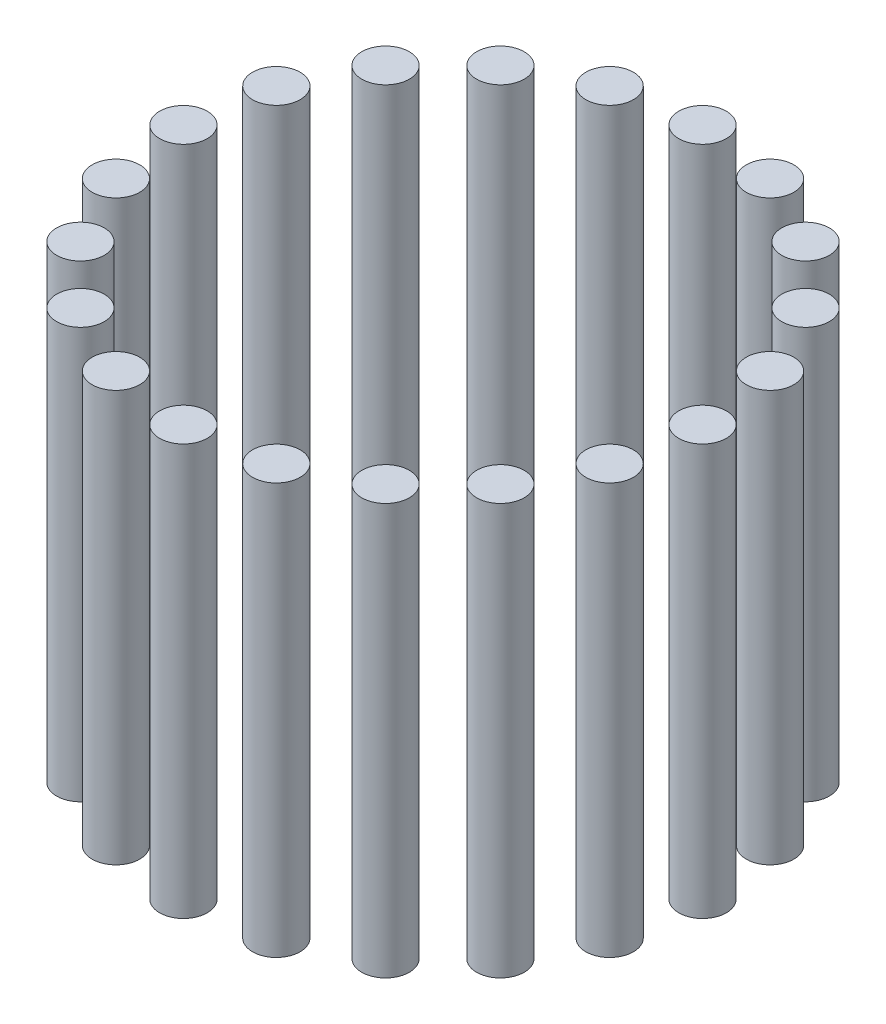
from build123d import *

# Parameters (mm, degrees)
SKETCH1_R              = 5.5
BOSS_EXTRUDE1_DEPTH    = 95
BOSS_EXTRUDE1_2_DEPTH  = 95
BOSS_EXTRUDE1_3_DEPTH  = 95
BOSS_EXTRUDE1_4_DEPTH  = 95
BOSS_EXTRUDE1_5_DEPTH  = 95
BOSS_EXTRUDE1_6_DEPTH  = 95
BOSS_EXTRUDE1_7_DEPTH  = 95
BOSS_EXTRUDE1_8_DEPTH  = 95
BOSS_EXTRUDE1_9_DEPTH  = 95
BOSS_EXTRUDE1_10_DEPTH = 95
BOSS_EXTRUDE1_11_DEPTH = 95
BOSS_EXTRUDE1_12_DEPTH = 95
BOSS_EXTRUDE1_13_DEPTH = 95
BOSS_EXTRUDE1_14_DEPTH = 95
BOSS_EXTRUDE1_15_DEPTH = 95
BOSS_EXTRUDE1_16_DEPTH = 95
BOSS_EXTRUDE1_17_DEPTH = 95
BOSS_EXTRUDE1_18_DEPTH = 95
BOSS_EXTRUDE1_19_DEPTH = 95
BOSS_EXTRUDE1_20_DEPTH = 95


with BuildPart() as part:
    # Sketch1 → Boss-Extrude1 (new body)
    with BuildSketch(Plane(origin=(0, 0, 0), x_dir=(1, 0, 0), z_dir=(0, 1, 0))):
        with Locations((-60, 0)):
            Circle(SKETCH1_R)
    extrude(amount=BOSS_EXTRUDE1_DEPTH)


with BuildPart() as body_2:
    # Sketch1 → Boss-Extrude1 2 (new body)
    with BuildSketch(Plane(origin=(0, 0, 0), x_dir=(1, 0, 0), z_dir=(0, 1, 0))):
        with Locations((-57.063390978, 18.541019662)):
            Circle(SKETCH1_R)
    extrude(amount=BOSS_EXTRUDE1_2_DEPTH)


with BuildPart() as body_3:
    # Sketch1 → Boss-Extrude1 3 (new body)
    with BuildSketch(Plane(origin=(0, 0, 0), x_dir=(1, 0, 0), z_dir=(0, 1, 0))):
        with Locations((-48.541019662, 35.267115138)):
            Circle(SKETCH1_R)
    extrude(amount=BOSS_EXTRUDE1_3_DEPTH)


with BuildPart() as body_4:
    # Sketch1 → Boss-Extrude1 4 (new body)
    with BuildSketch(Plane(origin=(0, 0, 0), x_dir=(1, 0, 0), z_dir=(0, 1, 0))):
        with Locations((-35.267115138, 48.541019662)):
            Circle(SKETCH1_R)
    extrude(amount=BOSS_EXTRUDE1_4_DEPTH)


with BuildPart() as body_5:
    # Sketch1 → Boss-Extrude1 5 (new body)
    with BuildSketch(Plane(origin=(0, 0, 0), x_dir=(1, 0, 0), z_dir=(0, 1, 0))):
        with Locations((-18.541019662, 57.063390978)):
            Circle(SKETCH1_R)
    extrude(amount=BOSS_EXTRUDE1_5_DEPTH)


with BuildPart() as body_6:
    # Sketch1 → Boss-Extrude1 6 (new body)
    with BuildSketch(Plane(origin=(0, 0, 0), x_dir=(1, 0, 0), z_dir=(0, 1, 0))):
        with Locations((0, 60)):
            Circle(SKETCH1_R)
    extrude(amount=BOSS_EXTRUDE1_6_DEPTH)


with BuildPart() as body_7:
    # Sketch1 → Boss-Extrude1 7 (new body)
    with BuildSketch(Plane(origin=(0, 0, 0), x_dir=(1, 0, 0), z_dir=(0, 1, 0))):
        with Locations((18.541019662, 57.063390978)):
            Circle(SKETCH1_R)
    extrude(amount=BOSS_EXTRUDE1_7_DEPTH)


with BuildPart() as body_8:
    # Sketch1 → Boss-Extrude1 8 (new body)
    with BuildSketch(Plane(origin=(0, 0, 0), x_dir=(1, 0, 0), z_dir=(0, 1, 0))):
        with Locations((35.267115138, 48.541019662)):
            Circle(SKETCH1_R)
    extrude(amount=BOSS_EXTRUDE1_8_DEPTH)


with BuildPart() as body_9:
    # Sketch1 → Boss-Extrude1 9 (new body)
    with BuildSketch(Plane(origin=(0, 0, 0), x_dir=(1, 0, 0), z_dir=(0, 1, 0))):
        with Locations((48.541019662, 35.267115138)):
            Circle(SKETCH1_R)
    extrude(amount=BOSS_EXTRUDE1_9_DEPTH)


with BuildPart() as body_10:
    # Sketch1 → Boss-Extrude1 10 (new body)
    with BuildSketch(Plane(origin=(0, 0, 0), x_dir=(1, 0, 0), z_dir=(0, 1, 0))):
        with Locations((57.063390978, 18.541019662)):
            Circle(SKETCH1_R)
    extrude(amount=BOSS_EXTRUDE1_10_DEPTH)


with BuildPart() as body_11:
    # Sketch1 → Boss-Extrude1 11 (new body)
    with BuildSketch(Plane(origin=(0, 0, 0), x_dir=(1, 0, 0), z_dir=(0, 1, 0))):
        with Locations((60, 0)):
            Circle(SKETCH1_R)
    extrude(amount=BOSS_EXTRUDE1_11_DEPTH)


with BuildPart() as body_12:
    # Sketch1 → Boss-Extrude1 12 (new body)
    with BuildSketch(Plane(origin=(0, 0, 0), x_dir=(1, 0, 0), z_dir=(0, 1, 0))):
        with Locations((57.063390978, -18.541019662)):
            Circle(SKETCH1_R)
    extrude(amount=BOSS_EXTRUDE1_12_DEPTH)


with BuildPart() as body_13:
    # Sketch1 → Boss-Extrude1 13 (new body)
    with BuildSketch(Plane(origin=(0, 0, 0), x_dir=(1, 0, 0), z_dir=(0, 1, 0))):
        with Locations((48.541019662, -35.267115138)):
            Circle(SKETCH1_R)
    extrude(amount=BOSS_EXTRUDE1_13_DEPTH)


with BuildPart() as body_14:
    # Sketch1 → Boss-Extrude1 14 (new body)
    with BuildSketch(Plane(origin=(0, 0, 0), x_dir=(1, 0, 0), z_dir=(0, 1, 0))):
        with Locations((35.267115138, -48.541019662)):
            Circle(SKETCH1_R)
    extrude(amount=BOSS_EXTRUDE1_14_DEPTH)


with BuildPart() as body_15:
    # Sketch1 → Boss-Extrude1 15 (new body)
    with BuildSketch(Plane(origin=(0, 0, 0), x_dir=(1, 0, 0), z_dir=(0, 1, 0))):
        with Locations((18.541019662, -57.063390978)):
            Circle(SKETCH1_R)
    extrude(amount=BOSS_EXTRUDE1_15_DEPTH)


with BuildPart() as body_16:
    # Sketch1 → Boss-Extrude1 16 (new body)
    with BuildSketch(Plane(origin=(0, 0, 0), x_dir=(1, 0, 0), z_dir=(0, 1, 0))):
        with Locations((0, -60)):
            Circle(SKETCH1_R)
    extrude(amount=BOSS_EXTRUDE1_16_DEPTH)


with BuildPart() as body_17:
    # Sketch1 → Boss-Extrude1 17 (new body)
    with BuildSketch(Plane(origin=(0, 0, 0), x_dir=(1, 0, 0), z_dir=(0, 1, 0))):
        with Locations((-18.541019662, -57.063390978)):
            Circle(SKETCH1_R)
    extrude(amount=BOSS_EXTRUDE1_17_DEPTH)


with BuildPart() as body_18:
    # Sketch1 → Boss-Extrude1 18 (new body)
    with BuildSketch(Plane(origin=(0, 0, 0), x_dir=(1, 0, 0), z_dir=(0, 1, 0))):
        with Locations((-35.267115138, -48.541019662)):
            Circle(SKETCH1_R)
    extrude(amount=BOSS_EXTRUDE1_18_DEPTH)


with BuildPart() as body_19:
    # Sketch1 → Boss-Extrude1 19 (new body)
    with BuildSketch(Plane(origin=(0, 0, 0), x_dir=(1, 0, 0), z_dir=(0, 1, 0))):
        with Locations((-48.541019662, -35.267115138)):
            Circle(SKETCH1_R)
    extrude(amount=BOSS_EXTRUDE1_19_DEPTH)


with BuildPart() as body_20:
    # Sketch1 → Boss-Extrude1 20 (new body)
    with BuildSketch(Plane(origin=(0, 0, 0), x_dir=(1, 0, 0), z_dir=(0, 1, 0))):
        with Locations((-57.063390978, -18.541019662)):
            Circle(SKETCH1_R)
    extrude(amount=BOSS_EXTRUDE1_20_DEPTH)


solid = Compound([part.part, body_2.part, body_3.part, body_4.part, body_5.part, body_6.part, body_7.part, body_8.part, body_9.part, body_10.part, body_11.part, body_12.part, body_13.part, body_14.part, body_15.part, body_16.part, body_17.part, body_18.part, body_19.part, body_20.part])
